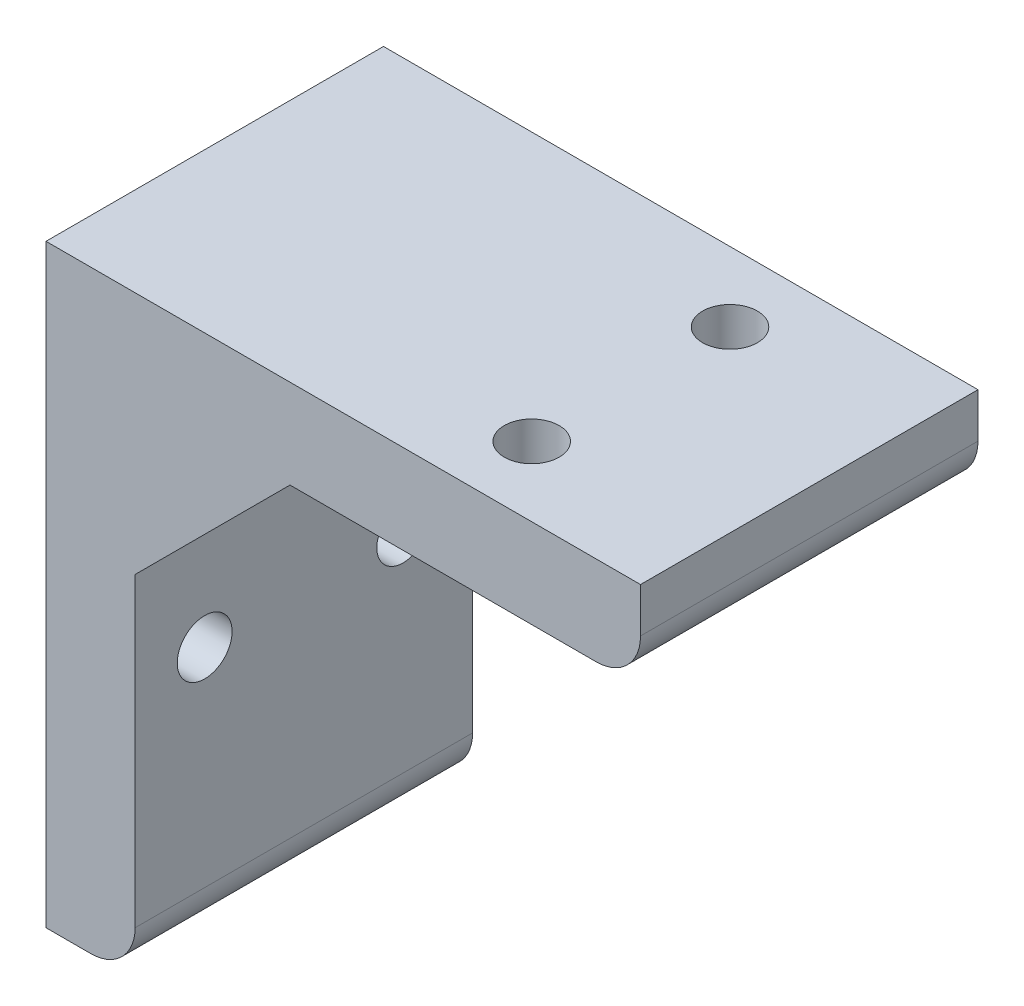
from build123d import *

# Parameters (mm, degrees)
SKETCH1_W           = 34.0614
SKETCH1_H           = 60
BOSS_EXTRUDE1_DEPTH = 8.9916
SKETCH2_W           = 34.0614
SKETCH2_H           = 8.9916
BOSS_EXTRUDE2_DEPTH = 51.0084
CUT_EXTRUDE2_REACH  = 10.992
SKETCH5_R           = 2.7686
SKETCH5_R_2         = 2.6416
CUT_EXTRUDE3_REACH  = 62
SKETCH6_R           = 2.7686
BOSS_EXTRUDE3_DEPTH = 34.0614
FILLET1_R           = 4.4958


with BuildPart() as part:
    # Sketch1 → Boss-Extrude1 (new body)
    with BuildSketch(Plane(origin=(0, 0, 0), x_dir=(0, 0, -1), z_dir=(1, 0, 0))):
        Rectangle(SKETCH1_W, SKETCH1_H)
    extrude(amount=BOSS_EXTRUDE1_DEPTH)

    # Sketch2 → Boss-Extrude2 (add)
    with BuildSketch(Plane(origin=(8.9916, 0, 0), x_dir=(0, 0, -1), z_dir=(1, 0, 0))):
        with Locations((0, 25.5042)):
            Rectangle(SKETCH2_W, SKETCH2_H)
    extrude(amount=BOSS_EXTRUDE2_DEPTH)

    # Sketch5 → Cut-Extrude2 (cut, up to next)
    with BuildSketch(Plane(origin=(8.9916, 0, 0), x_dir=(0, 0, -1), z_dir=(1, 0, 0)), mode=Mode.PRIVATE) as cut_extrude2_sk1:
        with Locations((-10.0076, -4.4958)):
            Circle(SKETCH5_R)
    cut_extrude2_tool1 = extrude(cut_extrude2_sk1.sketch, amount=-CUT_EXTRUDE2_REACH, mode=Mode.PRIVATE) & part.part
    add(cut_extrude2_tool1.solids().sort_by_distance((8.9916, -4.4958, 10.0076))[0], mode=Mode.SUBTRACT)
    # Sketch5 → Cut-Extrude2 (cut, up to next)
    with BuildSketch(Plane(origin=(8.9916, 0, 0), x_dir=(0, 0, -1), z_dir=(1, 0, 0)), mode=Mode.PRIVATE) as cut_extrude2_sk2:
        with Locations((10.0076, -4.4958)):
            Circle(SKETCH5_R_2)
    cut_extrude2_tool2 = extrude(cut_extrude2_sk2.sketch, amount=-CUT_EXTRUDE2_REACH, mode=Mode.PRIVATE) & part.part
    add(cut_extrude2_tool2.solids().sort_by_distance((8.9916, -4.4958, -10.0076))[0], mode=Mode.SUBTRACT)

    # Sketch6 → Cut-Extrude3 (cut, up to next)
    with BuildSketch(Plane(origin=(0, 30, 0), x_dir=(1, 0, 0), z_dir=(0, 1, 0)), mode=Mode.PRIVATE) as cut_extrude3_sk1:
        with Locations((41.995718, 10.0076)):
            Circle(SKETCH6_R)
    cut_extrude3_tool1 = extrude(cut_extrude3_sk1.sketch, amount=-CUT_EXTRUDE3_REACH, mode=Mode.PRIVATE) & part.part
    add(cut_extrude3_tool1.solids().sort_by_distance((41.995718, 30, -10.0076))[0], mode=Mode.SUBTRACT)
    # Sketch6 → Cut-Extrude3 (cut, up to next)
    with BuildSketch(Plane(origin=(0, 30, 0), x_dir=(1, 0, 0), z_dir=(0, 1, 0)), mode=Mode.PRIVATE) as cut_extrude3_sk2:
        with Locations((41.995718, -10.0076)):
            Circle(SKETCH6_R)
    cut_extrude3_tool2 = extrude(cut_extrude3_sk2.sketch, amount=-CUT_EXTRUDE3_REACH, mode=Mode.PRIVATE) & part.part
    add(cut_extrude3_tool2.solids().sort_by_distance((41.995718, 30, 10.0076))[0], mode=Mode.SUBTRACT)

    # Sketch7 → Boss-Extrude3 (add)
    with BuildSketch(Plane.XY.offset(17.0307)):
        Polygon((8.9916, 21.0084), (8.9916, 5.37450259), (24.62549741, 21.0084), align=None)
    extrude(amount=-BOSS_EXTRUDE3_DEPTH)

    # Fillet1
    fillet1_edges = [part.edges().sort_by_distance(p)[0] for p in [
        (8.9916, -30, 0),
        (60, 21.0084, 0),
    ]]
    fillet(fillet1_edges, radius=FILLET1_R)


solid = part.part
